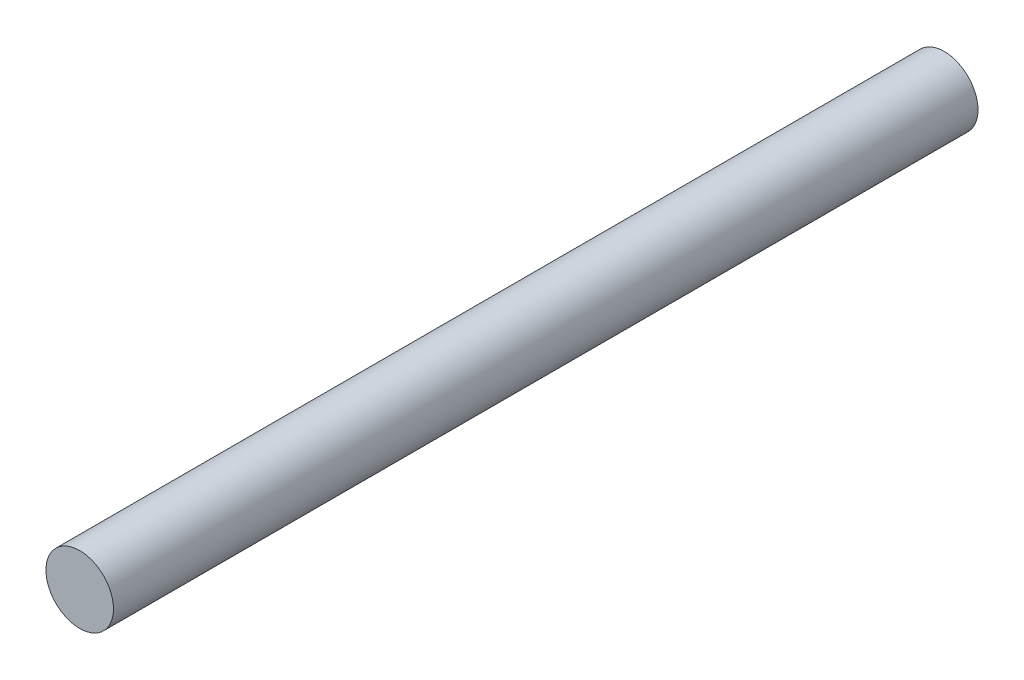
from build123d import *

# Parameters (mm, degrees)
SKETCH1_R           = 1.5875
BOSS_EXTRUDE1_DEPTH = 20.32


with BuildPart() as part:
    # Sketch1 → Boss-Extrude1 (new body, symmetric)
    with BuildSketch(Plane.XY):
        Circle(SKETCH1_R)
    extrude(amount=BOSS_EXTRUDE1_DEPTH, both=True)


solid = part.part
